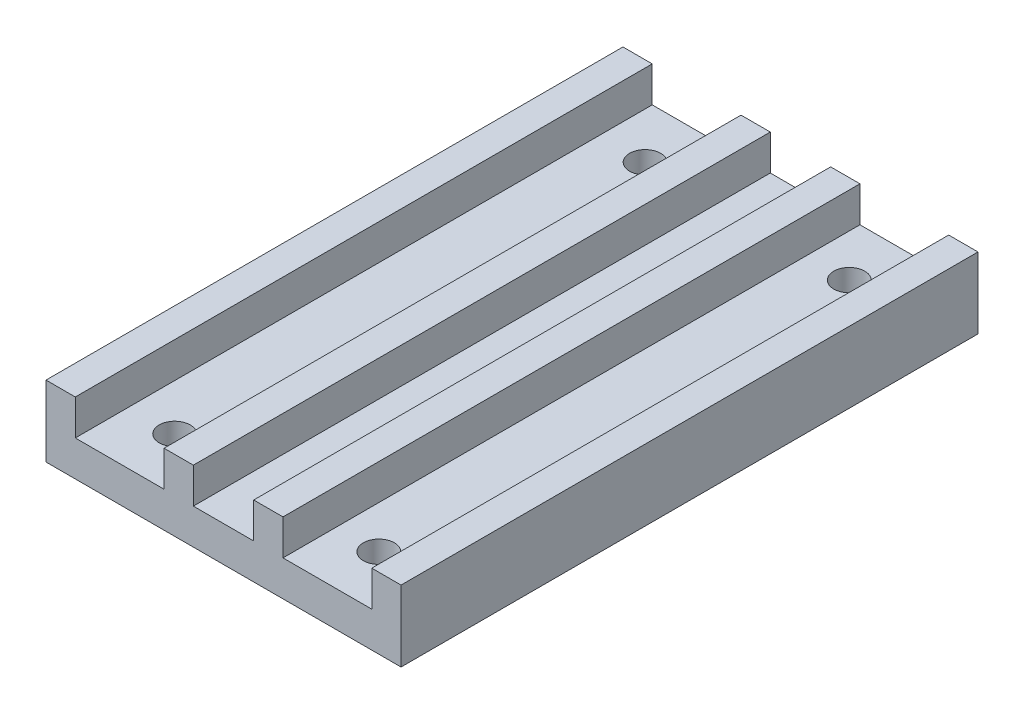
from build123d import *

# Parameters (mm, degrees)
SKETCH1_W           = 40
SKETCH1_H           = 65
SKETCH1_R           = 1.75
BOSS_EXTRUDE1_DEPTH = 4
SKETCH2_W           = 3.3
SKETCH2_H           = 65
BOSS_EXTRUDE2_DEPTH = 4


with BuildPart() as part:
    # Sketch1 → Boss-Extrude1 (new body)
    with BuildSketch(Plane(origin=(0, 0, 0), x_dir=(1, 0, 0), z_dir=(0, 1, 0))):
        Rectangle(SKETCH1_W, SKETCH1_H)
        with Locations((11.5, -26.5)):
            Circle(SKETCH1_R, mode=Mode.SUBTRACT)
        with Locations((-11.5, -26.5)):
            Circle(SKETCH1_R, mode=Mode.SUBTRACT)
        with Locations((11.5, 26.5)):
            Circle(SKETCH1_R, mode=Mode.SUBTRACT)
        with Locations((-11.5, 26.5)):
            Circle(SKETCH1_R, mode=Mode.SUBTRACT)
    extrude(amount=BOSS_EXTRUDE1_DEPTH)

    # Sketch2 → Boss-Extrude2 (add)
    with BuildSketch(Plane(origin=(0, 4, 0), x_dir=(1, 0, 0), z_dir=(0, 1, 0))):
        with Locations((-18.35, 0)):
            Rectangle(SKETCH2_W, SKETCH2_H)
        with Locations((18.35, 0)):
            Rectangle(SKETCH2_W, SKETCH2_H)
        with Locations((-5.05, 0)):
            Rectangle(SKETCH2_W, SKETCH2_H)
        with Locations((5.05, 0)):
            Rectangle(SKETCH2_W, SKETCH2_H)
    extrude(amount=BOSS_EXTRUDE2_DEPTH)


solid = part.part
